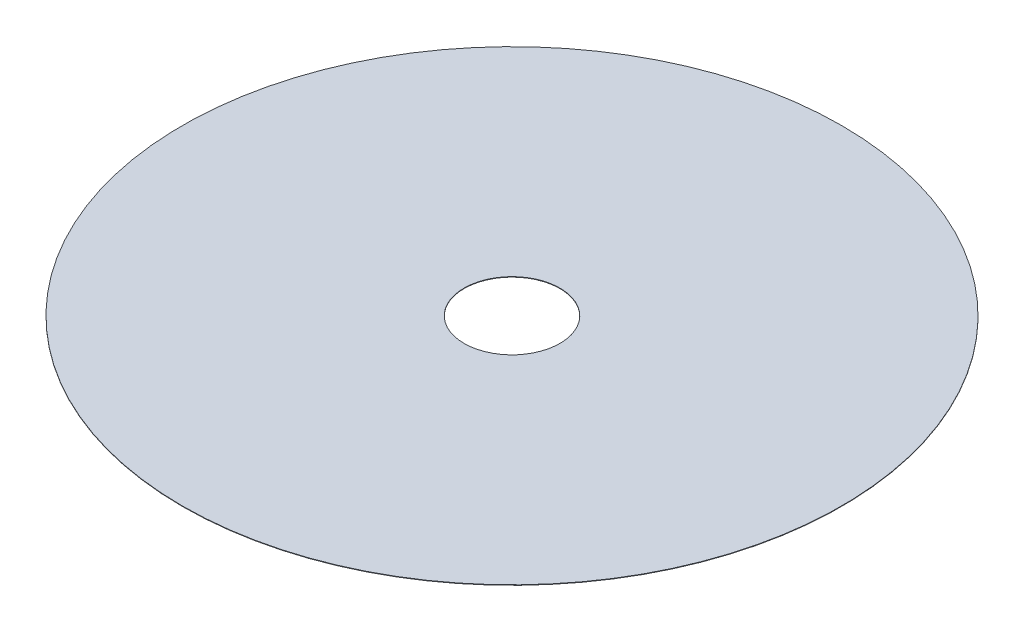
from build123d import *

# Parameters (mm, degrees)
SKETCH1_R           = 27500
BOSS_EXTRUDE1_DEPTH = 38.1
SKETCH2_R           = 4000
CUT_EXTRUDE1_DEPTH  = 38.1


with BuildPart() as part:
    # Sketch1 → Boss-Extrude1 (new body)
    with BuildSketch(Plane(origin=(0, 0, 0), x_dir=(1, 0, 0), z_dir=(0, 1, 0))):
        Circle(SKETCH1_R)
    extrude(amount=BOSS_EXTRUDE1_DEPTH)

    # Sketch2 → Cut-Extrude1 (cut)
    with BuildSketch(Plane(origin=(0, 38.1, 0), x_dir=(1, 0, 0), z_dir=(0, 1, 0))):
        Circle(SKETCH2_R)
    extrude(amount=-CUT_EXTRUDE1_DEPTH, mode=Mode.SUBTRACT)


solid = part.part
